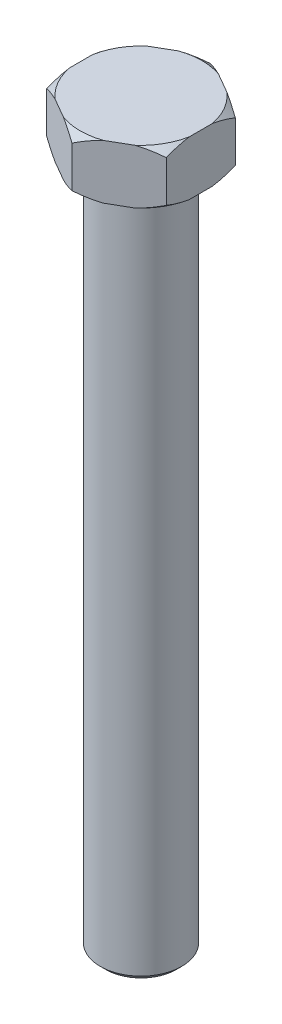
from build123d import *

# Parameters (mm, degrees)
BOSS_EXTRUDE1_DEPTH = 10
SKETCH2_R           = 7.5
BOSS_EXTRUDE2_DEPTH = 126
CHAMFER1_SIZE       = 1


with BuildPart() as part:
    # Sketch1 → Boss-Extrude1 (new body)
    with BuildSketch(Plane(origin=(0, 0, 0), x_dir=(1, 0, 0), z_dir=(0, 1, 0))):
        Polygon((0, 12.701705922), (-11, 6.350852961), (-11, -6.350852961), (0, -12.701705922), (11, -6.350852961), (11, 6.350852961), align=None)
    extrude(amount=BOSS_EXTRUDE1_DEPTH)

    # Sketch2 → Boss-Extrude2 (add)
    with BuildSketch(Plane.XZ):
        Circle(SKETCH2_R)
    extrude(amount=BOSS_EXTRUDE2_DEPTH)

    # Sketch4 → Cut-Revolve2 (revolve, cut)
    with BuildSketch(Plane(origin=(0, 0, 0), x_dir=(0, 0, -1), z_dir=(1, 0, 0))):
        Polygon((-12.701705922, 10), (-12.701705922, 8.8), (-11.201705922, 10), align=None)
        Polygon((-12.701705922, 0), (-12.701705922, 1.2), (-11.201705922, 0), align=None)
    revolve(axis=Axis((0, 0, 0), (0, 1, 0)), mode=Mode.SUBTRACT)

    # Chamfer1
    chamfer1_edges = [part.edges().sort_by_distance(p)[0] for p in [
        (-7.5, -126, 0),
    ]]
    chamfer(chamfer1_edges, length=CHAMFER1_SIZE)


solid = part.part
